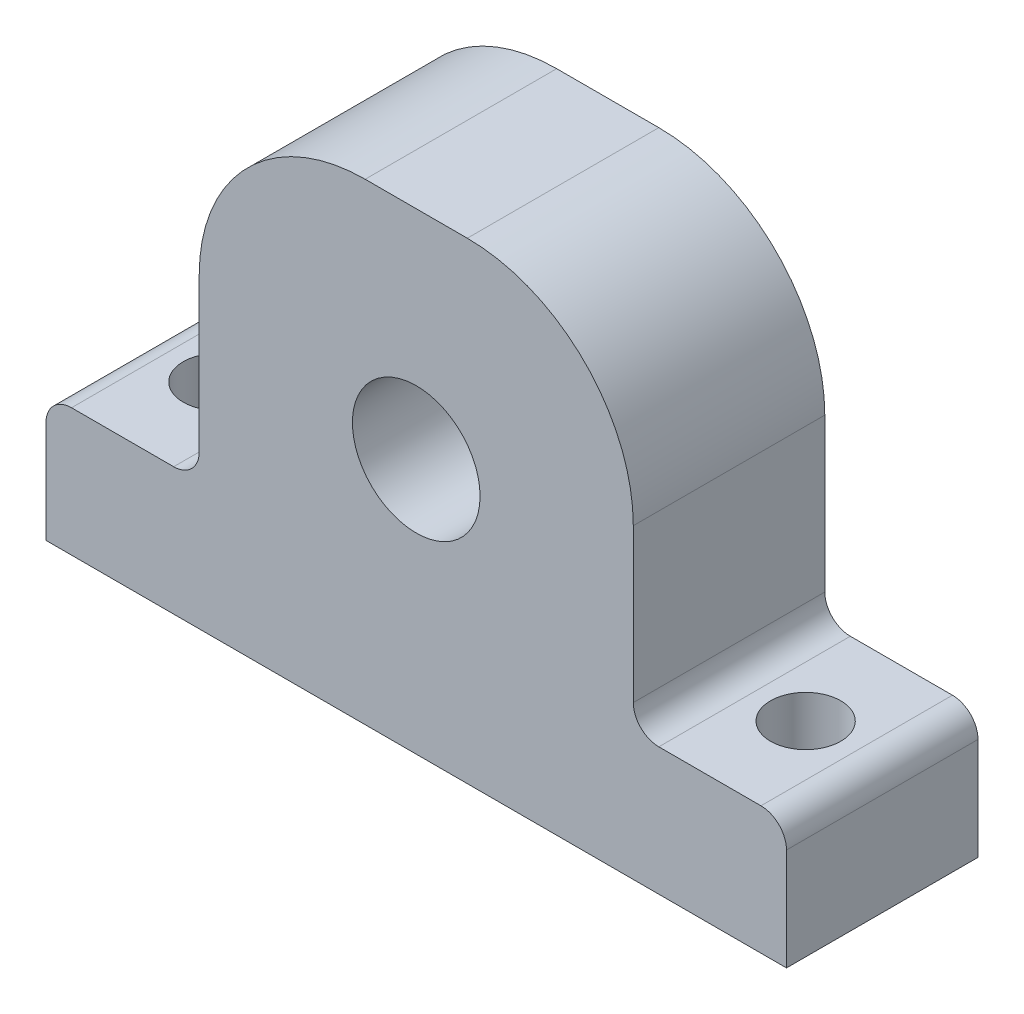
from build123d import *

# Parameters (mm, degrees)
SKETCH_1_W          = 58
SKETCH_1_H          = 10
SKETCH_1_W_2        = 34
SKETCH_1_H_2        = 27
SKETCH_1_R          = 5
EXTRUDE_1_DEPTH     = 15
SKETCH_2_R          = 2.75
CUT_EXTRUDE_1_DEPTH = 15
FILLET_2_R          = 13
FILLET_3_R          = 2


with BuildPart() as part:
    # 草图1 → 凸台-拉伸1 (new body)
    with BuildSketch(Plane.XY):
        Rectangle(SKETCH_1_W, SKETCH_1_H)
        with Locations((0, 18.5)):
            Rectangle(SKETCH_1_W_2, SKETCH_1_H_2)
        with Locations((0, 15)):
            Circle(SKETCH_1_R, mode=Mode.SUBTRACT)
    extrude(amount=EXTRUDE_1_DEPTH)

    # 草图2 → 切除-拉伸1 (cut)
    with BuildSketch(Plane(origin=(0, 5, 0), x_dir=(1, 0, 0), z_dir=(0, 1, 0))):
        with Locations((-23, -7.5)):
            Circle(SKETCH_2_R)
        with Locations((23, -7.5)):
            Circle(SKETCH_2_R)
    extrude(amount=-CUT_EXTRUDE_1_DEPTH, mode=Mode.SUBTRACT)

    # 圆角2
    fillet_2_edges = [part.edges().sort_by_distance(p)[0] for p in [
        (-17, 32, 7.5),
        (17, 32, 7.5),
    ]]
    fillet(fillet_2_edges, radius=FILLET_2_R)

    # 圆角3
    fillet_3_edges = [part.edges().sort_by_distance(p)[0] for p in [
        (-29, 5, 7.5),
        (-17, 5, 7.5),
        (17, 5, 7.5),
        (29, 5, 7.5),
    ]]
    fillet(fillet_3_edges, radius=FILLET_3_R)


solid = part.part
